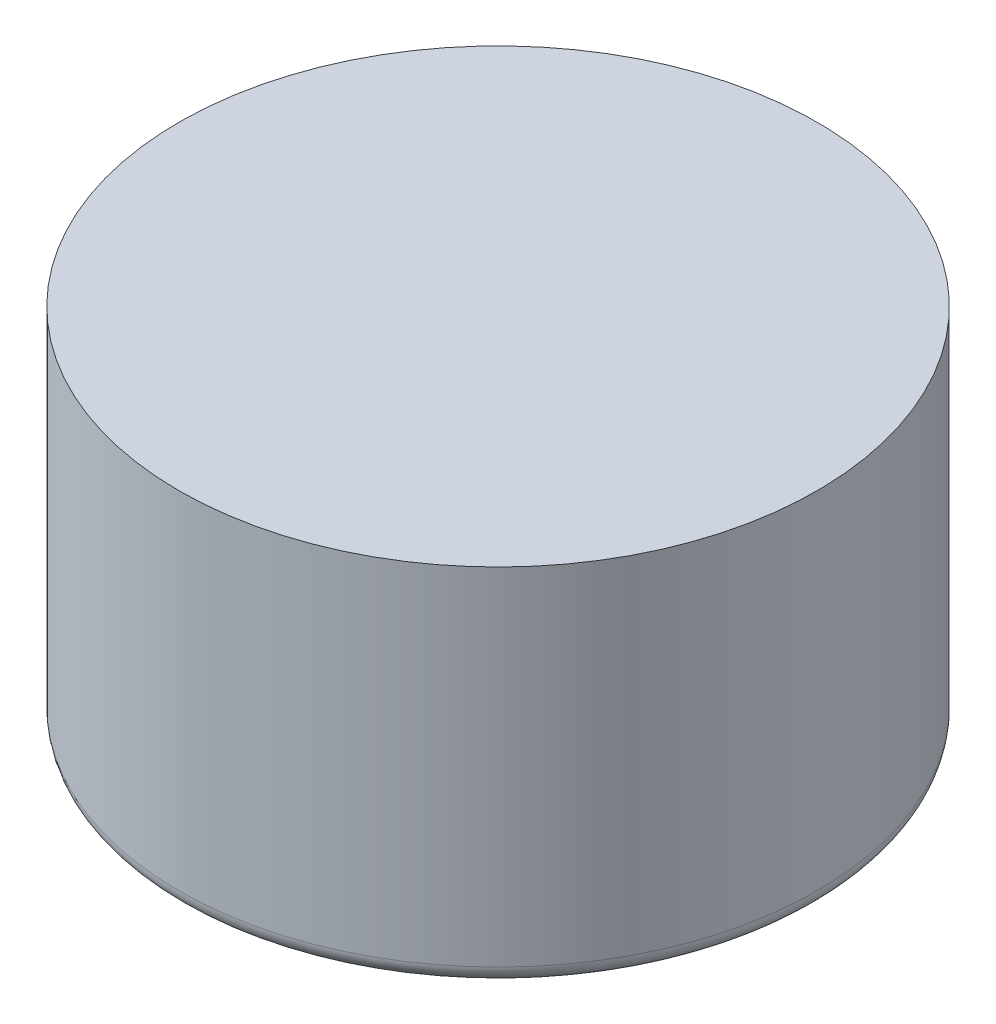
from build123d import *

# Parameters (mm, degrees)
SKETCH1_R           = 1.75
BOSS_EXTRUDE1_DEPTH = 2
FILLET3_R           = 0.1


with BuildPart() as part:
    # Sketch1 → Boss-Extrude1 (new body)
    with BuildSketch(Plane(origin=(0, 0, 0), x_dir=(1, 0, 0), z_dir=(0, 1, 0))):
        Circle(SKETCH1_R)
    extrude(amount=BOSS_EXTRUDE1_DEPTH)

    # Fillet3
    fillet3_edges = [part.edges().sort_by_distance(p)[0] for p in [
        (-1.75, 0, 0),
    ]]
    fillet(fillet3_edges, radius=FILLET3_R)


solid = part.part
